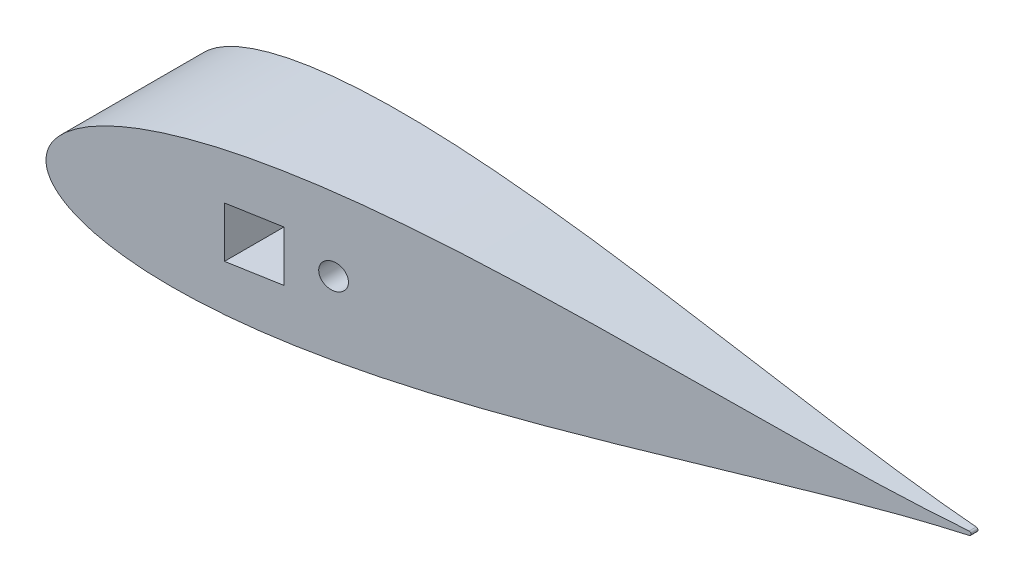
from build123d import *

# Parameters (mm, degrees)
BOSS_EXTRUDE1_DEPTH      = 127
SCALE1_SCALE             = 0.46
SKETCH10_R               = 4.7625
SKETCH10_W               = 19.05
SKETCH10_H               = 19.05
CUT_EXTRUDE6_DEPTH       = 59.4200001
CUT_EXTRUDE11_DEPTH      = 28.762405604
CUT_EXTRUDE11_DEPTH_BACK = 28.762405604


with BuildPart() as part:
    # Sketch2 → Boss-Extrude1 (new body)
    with BuildSketch(Plane.XY):
        with BuildLine():
            add(Edge.make_bspline(
                [(642.510849283, 1.582039112), (641.993392355, 1.625070631), (638.093728429, 1.953546407), (630.413817462, 2.663385493), (619.014124193, 3.849253664), (606.374988512, 5.304428983), (592.543922516, 7.037634907), (577.585454095, 9.050636147), (561.564270734, 11.338919625), (544.549749946, 13.890665375), (526.614143658, 16.687720753), (507.832591566, 19.705111663), (488.282710288, 22.911672601), (468.044367735, 26.27043606), (447.199424328, 29.739007432), (425.831595832, 33.270324121), (404.02631566, 36.813220545), (381.870662856, 40.313266856), (359.453314895, 43.713502532), (336.86454415, 46.955447457), (314.196207315, 49.979843895), (291.541767704, 52.727712704), (268.996310773, 55.141201012), (246.65655865, 57.164603829), (224.620860897, 58.745176641), (202.989192599, 59.8341217), (181.863132616, 60.387506142), (161.345829027, 60.366961324), (141.542033828, 59.739895824), (122.558104573, 58.481758104), (104.502313427, 56.574303932), (87.485018636, 54.008935199), (71.619696083, 50.784752003), (57.023709725, 46.912543066), (43.82045433, 42.41500246), (32.141645239, 37.332204029), (22.129107375, 31.731455339), (13.932423524, 25.726412106), (7.689616489, 19.513207632), (3.463136343, 13.420354421), (1.106333228, 7.923389435), (0.154611582, 3.513796615), (-0.062151598, 0), (0.154611582, -3.513796615), (1.106333228, -7.923389435), (3.463136343, -13.420354421), (7.689616489, -19.513207632), (13.932423524, -25.726412106), (22.129107375, -31.731455339), (32.141645239, -37.332204029), (43.82045433, -42.41500246), (57.023709725, -46.912543066), (71.619696083, -50.784752003), (87.485018636, -54.008935199), (104.502313427, -56.574303932), (122.558104573, -58.481758104), (141.542033828, -59.739895824), (161.345829027, -60.366961324), (181.863132616, -60.387506142), (202.989192599, -59.8341217), (224.620860897, -58.745176641), (246.65655865, -57.164603829), (268.996310773, -55.141201012), (291.541767704, -52.727712704), (314.196207315, -49.979843895), (336.86454415, -46.955447457), (359.453314895, -43.713502532), (381.870662856, -40.313266856), (404.02631566, -36.813220545), (425.831595832, -33.270324121), (447.199424328, -29.739007432), (468.044367735, -26.27043606), (488.282710288, -22.911672601), (507.832591566, -19.705111663), (526.614143658, -16.687720753), (544.549749946, -13.890665375), (561.564270734, -11.338919625), (577.585454095, -9.050636147), (592.543922516, -7.037634907), (606.374988512, -5.304428983), (619.014124193, -3.849253664), (630.413817462, -2.663385493), (638.093728429, -1.953546407), (641.993392355, -1.625070631), (642.510849283, -1.582039112)],
                knots=[0.020157042, 0.020157042, 0.020157042, 0.020157042, 0.021270888, 0.028552555, 0.036780684, 0.045920102, 0.055931764, 0.066772884, 0.07839713, 0.090754827, 0.103793165, 0.117456432, 0.131686226, 0.146421738, 0.161599998, 0.177156133, 0.193023668, 0.209134786, 0.225420633, 0.241811602, 0.258237647, 0.274628557, 0.290914287, 0.307025229, 0.322892517, 0.338448342, 0.353626207, 0.368361232, 0.382590428, 0.396252961, 0.409290412, 0.42164701, 0.433269881, 0.444109249, 0.45411864, 0.463255055, 0.471479114, 0.478755289, 0.485052318, 0.490344026, 0.494609833, 0.497833231, 0.5, 0.502166769, 0.505390167, 0.509655974, 0.514947682, 0.521244711, 0.528520886, 0.536744945, 0.54588136, 0.555890751, 0.566730119, 0.57835299, 0.590709588, 0.603747039, 0.617409572, 0.631638768, 0.646373793, 0.661551658, 0.677107483, 0.692974771, 0.709085713, 0.725371443, 0.741762353, 0.758188398, 0.774579367, 0.790865214, 0.806976332, 0.822843867, 0.838400002, 0.853578262, 0.868313774, 0.882543568, 0.896206835, 0.909245173, 0.92160287, 0.933227116, 0.944068236, 0.954079898, 0.963219316, 0.971447445, 0.978729112, 0.979842958, 0.979842958, 0.979842958, 0.979842958], degree=3))
            ThreePointArc((642.510849283, -1.582039112), (643.966787522, 0), (642.510849283, 1.582039112))
        make_face()
    extrude(amount=BOSS_EXTRUDE1_DEPTH)


with BuildPart() as part_1:
    # Scale1: scaled about (0, 0, 0)
    add(part.part.scale(SCALE1_SCALE))

    # Sketch10 → Cut-Extrude6 (cut, through all)
    with BuildSketch(Plane.XY.offset(58.42)):
        with Locations((92.075, 0)):
            Circle(SKETCH10_R)
        with Locations((66.675, 0)):
            Rectangle(SKETCH10_W, SKETCH10_H)
    extrude(amount=-CUT_EXTRUDE6_DEPTH, mode=Mode.SUBTRACT)

    # Sketch13 → Cut-Extrude11 (cut, two sides)
    with BuildSketch(Plane(origin=(0, 0, 0), x_dir=(1, 0, 0), z_dir=(0, 1, 0))) as cut_extrude11_sk:
        Polygon((0, -54.772410887), (296.22472226, -2.54), (296.22472226, -58.42), (0, -58.42), align=None)
    extrude(amount=CUT_EXTRUDE11_DEPTH, mode=Mode.SUBTRACT)
    extrude(cut_extrude11_sk.sketch, amount=-CUT_EXTRUDE11_DEPTH_BACK, mode=Mode.SUBTRACT)


solid = part_1.part
